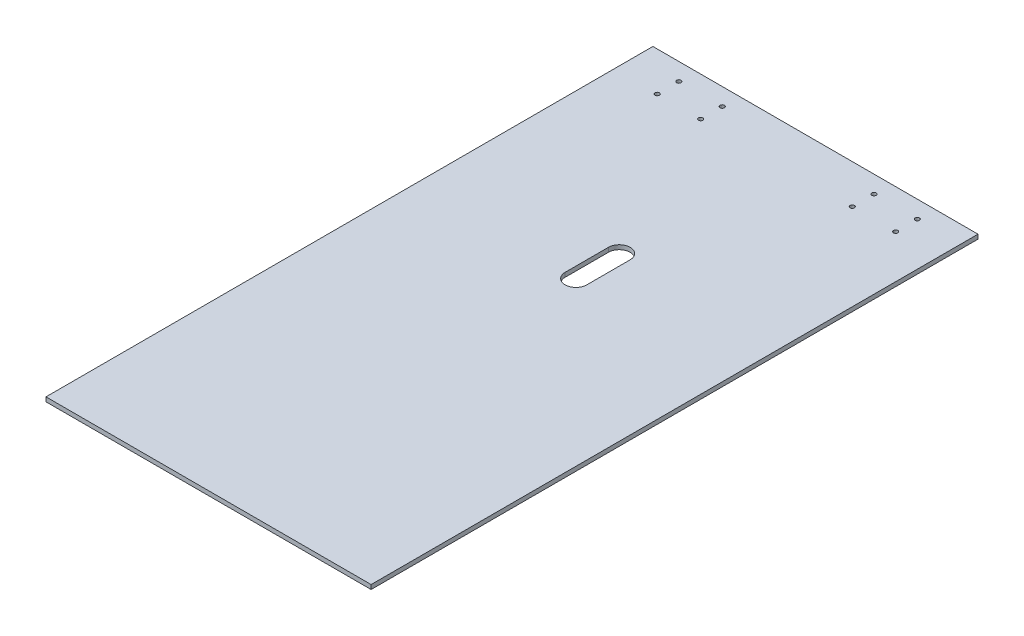
from build123d import *

# Parameters (mm, degrees)
SKETCH_1_W                  = 150
SKETCH_1_H                  = 280
EXTRUDE_1_DEPTH             = 2
SKETCH_4_R                  = 1
CUT_EXTRUDE_1_DEPTH         = 2
PATTERN_LINEAR_1_COUNT      = 2
PATTERN_LINEAR_1_PITCH      = 20
PATTERN_LINEAR_1_COUNT_DIR2 = 2
PATTERN_LINEAR_1_PITCH_DIR2 = 10
MIRROR_2_COPY_1_SKETCH_R    = 1
MIRROR_2_COPY_1_DEPTH       = 2
MIRROR_2_COPY_2_SKETCH_R    = 1
MIRROR_2_COPY_2_DEPTH       = 2
MIRROR_2_COPY_3_SKETCH_R    = 1
MIRROR_2_COPY_3_DEPTH       = 2
CUT_EXTRUDE_2_DEPTH         = 10


with BuildPart() as part:
    # 草图1 → 凸台-拉伸1 (new body)
    with BuildSketch(Plane(origin=(0, 0, 0), x_dir=(1, 0, 0), z_dir=(0, 1, 0))):
        Rectangle(SKETCH_1_W, SKETCH_1_H)
    extrude(amount=EXTRUDE_1_DEPTH)

    # 草图4 → 切除-拉伸1 (cut)
    with BuildSketch(Plane(origin=(0, 2, 0), x_dir=(1, 0, 0), z_dir=(0, 1, 0))):
        with Locations((-55, 132)):
            Circle(SKETCH_4_R)
    cut_extrude_1 = extrude(amount=-CUT_EXTRUDE_1_DEPTH, mode=Mode.SUBTRACT)

    # 阵列(线性)1: Cut-Extrude 1 2 × 2
    with Locations(*[(i * PATTERN_LINEAR_1_PITCH, 0, j * PATTERN_LINEAR_1_PITCH_DIR2) for i in range(PATTERN_LINEAR_1_COUNT) for j in range(PATTERN_LINEAR_1_COUNT_DIR2) if (i, j) != (0, 0)]):
        add(cut_extrude_1, mode=Mode.SUBTRACT)

    # 镜向2: 切除-拉伸1 across plane
    add(cut_extrude_1.mirror(Plane.ZY), mode=Mode.SUBTRACT)

    # 镜向2 copy 1 sketch → 镜向2 copy 1 (cut)
    with BuildSketch(Plane(origin=(0, 2, 10), x_dir=(-1, 0, 0), z_dir=(0, 1, 0))):
        with Locations((-55, -132)):
            Circle(MIRROR_2_COPY_1_SKETCH_R)
    extrude(amount=-MIRROR_2_COPY_1_DEPTH, mode=Mode.SUBTRACT)

    # 镜向2 copy 2 sketch → 镜向2 copy 2 (cut)
    with BuildSketch(Plane(origin=(-20, 2, 0), x_dir=(-1, 0, 0), z_dir=(0, 1, 0))):
        with Locations((-55, -132)):
            Circle(MIRROR_2_COPY_2_SKETCH_R)
    extrude(amount=-MIRROR_2_COPY_2_DEPTH, mode=Mode.SUBTRACT)

    # 镜向2 copy 3 sketch → 镜向2 copy 3 (cut)
    with BuildSketch(Plane(origin=(-20, 2, 10), x_dir=(-1, 0, 0), z_dir=(0, 1, 0))):
        with Locations((-55, -132)):
            Circle(MIRROR_2_COPY_3_SKETCH_R)
    extrude(amount=-MIRROR_2_COPY_3_DEPTH, mode=Mode.SUBTRACT)

    # 草图5 → 切除-拉伸2 (cut)
    with BuildSketch(Plane(origin=(0, 2, 0), x_dir=(1, 0, 0), z_dir=(0, 1, 0))):
        with BuildLine():
            Line((5, 49.5), (5, 29.5))
            ThreePointArc((5, 29.5), (0, 24.5), (-5, 29.5))
            Line((-5, 29.5), (-5, 49.5))
            ThreePointArc((-5, 49.5), (0, 54.5), (5, 49.5))
        make_face()
    extrude(amount=-CUT_EXTRUDE_2_DEPTH, mode=Mode.SUBTRACT)


solid = part.part
